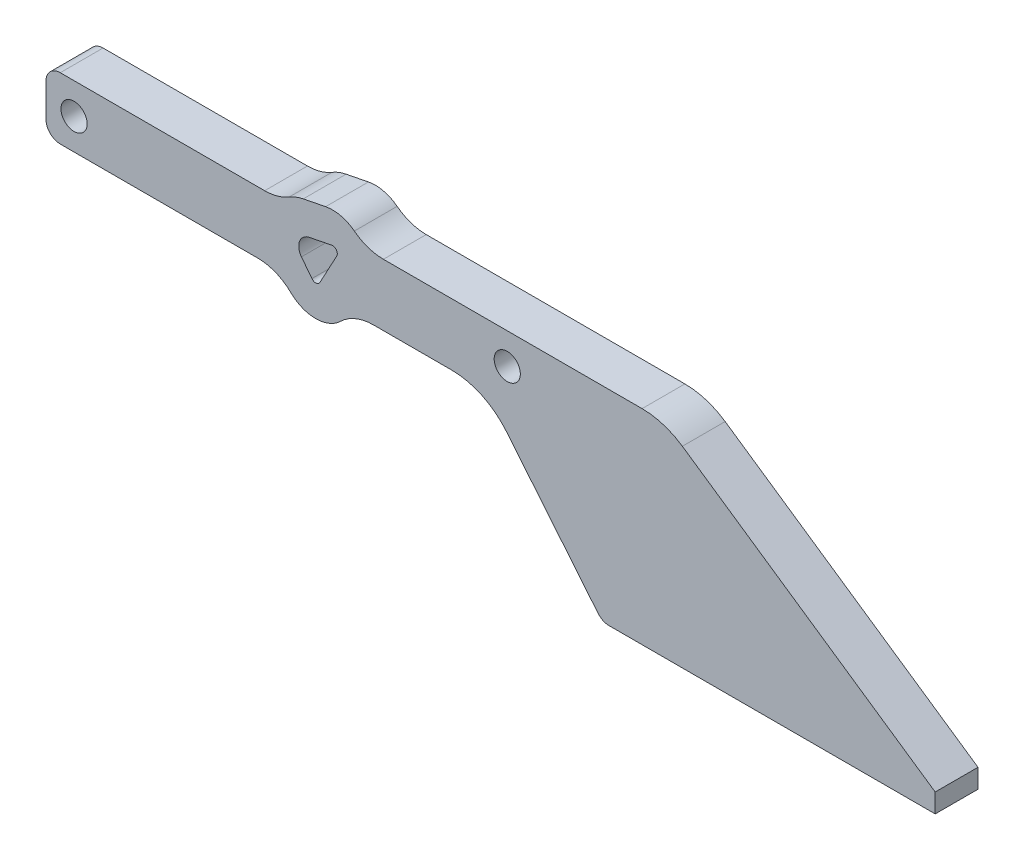
from build123d import *

# Parameters (mm, degrees)
SKETCH3_R           = 2.75
BOSS_EXTRUDE3_DEPTH = 4.5
FILLET13_R          = 15
FILLET14_R          = 10
FILLET15_R          = 3


with BuildPart() as part:
    # Sketch3 → Boss-Extrude3 (new body, symmetric)
    with BuildSketch(Plane.XY):
        with BuildLine():
            Line((-70, 0), (0, 0))
            Line((0, 0), (0, 4))
            Line((0, 4), (-57, 43))
            Line((-57, 43), (-120.301993943, 43))
            ThreePointArc((-120.301993943, 43), (-123.692897096, 46.002238478), (-128.193883581, 46.505011528))
            Line((-128.193883581, 46.505011528), (-132.896667749, 45.573835187))
            ThreePointArc((-132.896667749, 45.573835187), (-135.482170861, 44.646108184), (-137.681223291, 43))
            Line((-137.681223291, 43), (-187, 43))
            Line((-187, 43), (-187, 30))
            Line((-187, 30), (-137.769349371, 30))
            Line((-137.769349371, 30), (-136.22697347, 27.997184072))
            ThreePointArc((-136.22697347, 27.997184072), (-129.680147263, 25.097686291), (-123.684421639, 29.011673389))
            Line((-123.684421639, 29.011673389), (-123.151115414, 30))
            Line((-123.151115414, 30), (-94.638255551, 30))
            Line((-94.638255551, 30), (-70, 0))
        make_face()
        with Locations((-90, 36.5)):
            Circle(SKETCH3_R, mode=Mode.SUBTRACT)
        with BuildLine():
            ThreePointArc((-133.278796519, 34.822100799), (-133.674163723, 37.467564533), (-131.634144466, 39.197626677))
            Line((-131.634144466, 39.197626677), (-126.931360298, 40.128803018))
            ThreePointArc((-126.931360298, 40.128803018), (-125.932483215, 39.741607136), (-125.857075346, 38.672967941))
            Line((-125.857075346, 38.672967941), (-129.404750544, 32.09839288))
            ThreePointArc((-129.404750544, 32.09839288), (-130.204180628, 31.576527934), (-131.077090788, 31.963127638))
            Line((-131.077090788, 31.963127638), (-133.278796519, 34.822100799))
        make_face(mode=Mode.SUBTRACT)
        with Locations((-181.1, 36.5)):
            Circle(SKETCH3_R, mode=Mode.SUBTRACT)
    extrude(amount=BOSS_EXTRUDE3_DEPTH, both=True)

    # Fillet13
    fillet13_edges = [part.edges().sort_by_distance(p)[0] for p in [
        (-57, 43, 0),
        (-94.638255551, 30, 0),
    ]]
    fillet(fillet13_edges, radius=FILLET13_R)

    # Fillet14
    fillet14_edges = [part.edges().sort_by_distance(p)[0] for p in [
        (-120.301993943, 43, 0),
        (-137.681223291, 43, 0),
        (-137.769349371, 30, 0),
        (-123.151115414, 30, 0),
    ]]
    fillet(fillet14_edges, radius=FILLET14_R)

    # Fillet15
    fillet15_edges = [part.edges().sort_by_distance(p)[0] for p in [
        (-70, 0, 0),
        (-187, 30, 0),
        (-187, 43, 0),
    ]]
    fillet(fillet15_edges, radius=FILLET15_R)


solid = part.part
